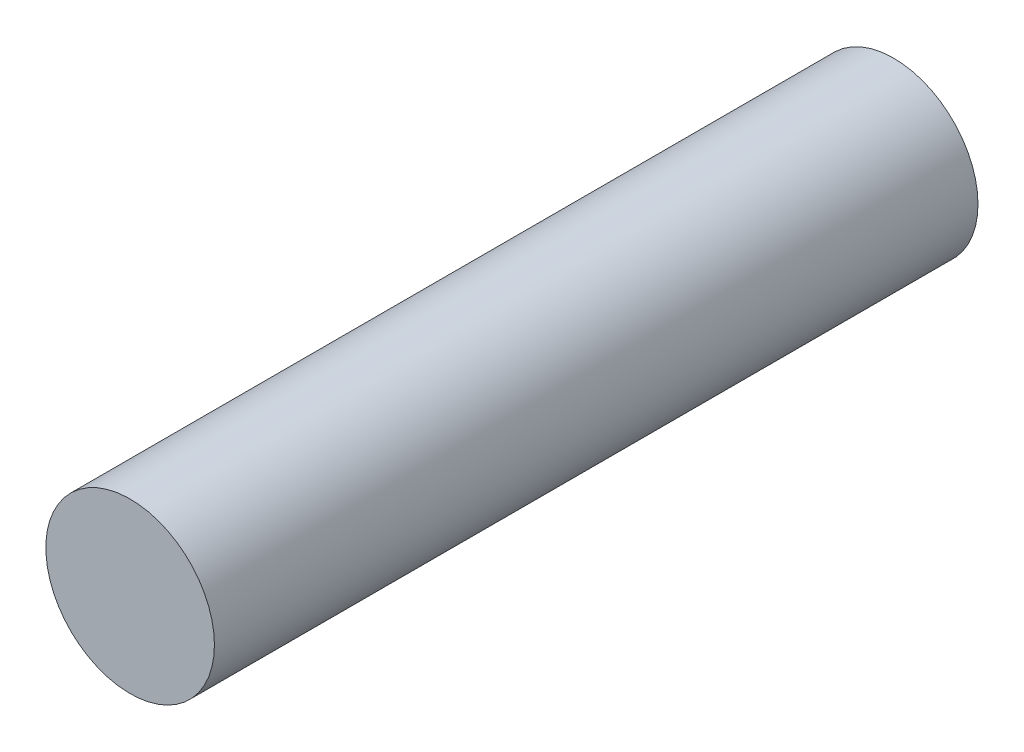
from build123d import *

# Parameters (mm, degrees)
SKETCH1_R           = 39.2557
BOSS_EXTRUDE1_DEPTH = 177.8


with BuildPart() as part:
    # Sketch1 → Boss-Extrude1 (new body, symmetric)
    with BuildSketch(Plane.XY):
        Circle(SKETCH1_R)
    extrude(amount=BOSS_EXTRUDE1_DEPTH, both=True)


solid = part.part
